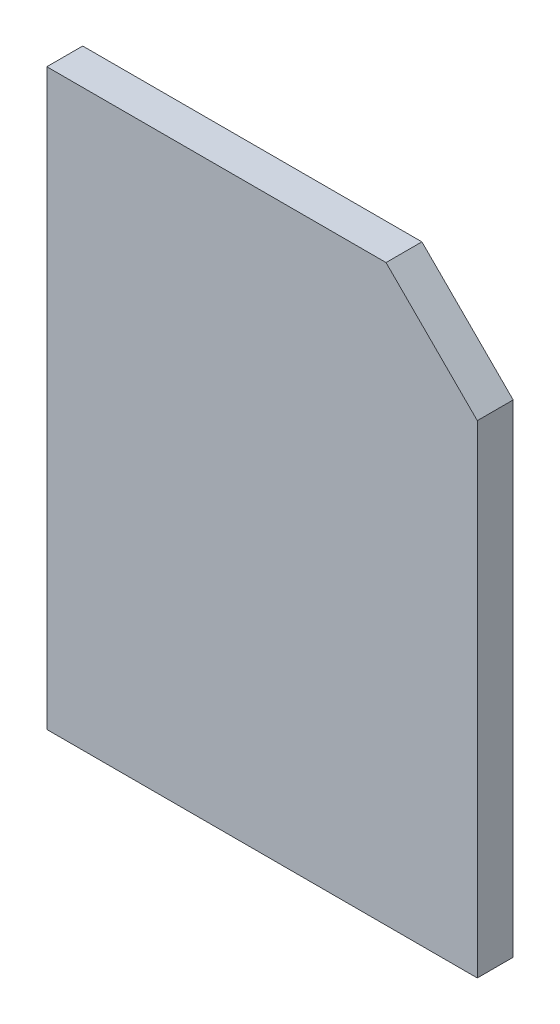
from build123d import *

# Parameters (mm, degrees)
SKETCH_1_W          = 24
SKETCH_1_H          = 32
EXTRUDE_1_DEPTH     = 2
CUT_EXTRUDE_1_DEPTH = 2


with BuildPart() as part:
    # 草图1 → 凸台-拉伸1 (new body)
    with BuildSketch(Plane.XY):
        Rectangle(SKETCH_1_W, SKETCH_1_H)
    extrude(amount=EXTRUDE_1_DEPTH)

    # 草图2 → 切除-拉伸1 (cut)
    with BuildSketch(Plane.XY.offset(2)):
        Polygon((6.911688245, 16), (12, 10.911688245), (12, 16), align=None)
    extrude(amount=-CUT_EXTRUDE_1_DEPTH, mode=Mode.SUBTRACT)


solid = part.part
